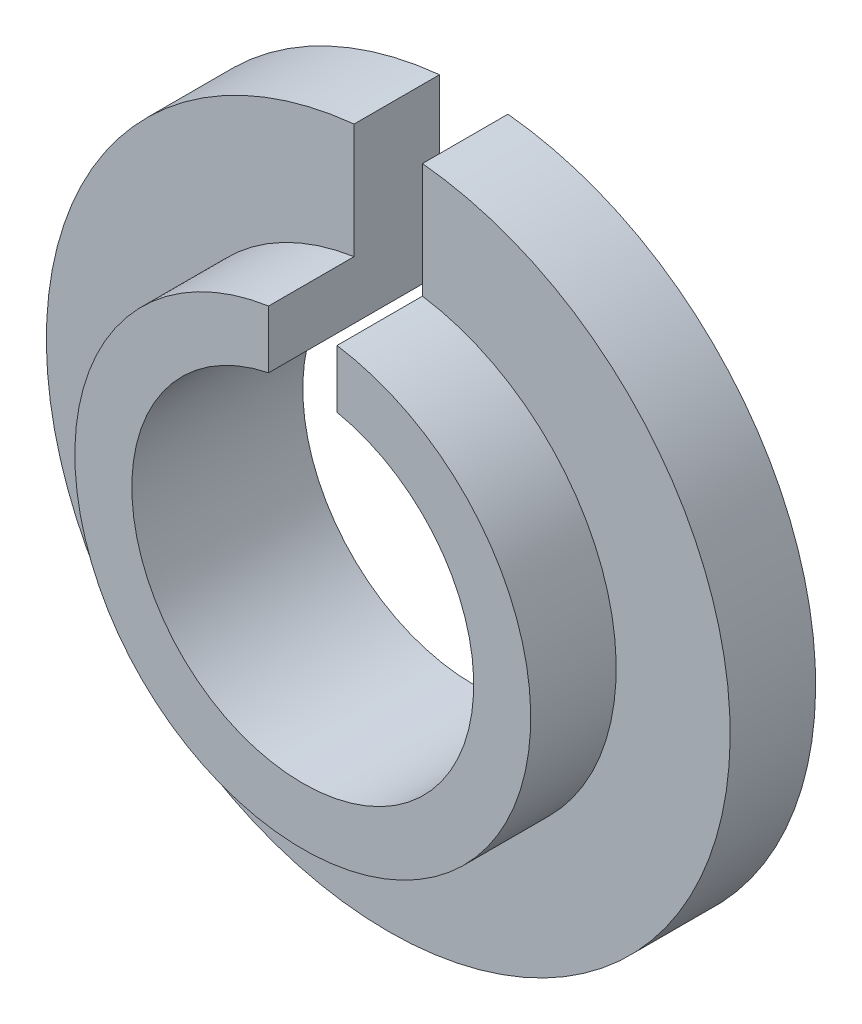
from build123d import *

# Parameters (mm, degrees)
SKETCH1_R           = 20
SKETCH1_R_2         = 15
BOSS_EXTRUDE1_DEPTH = 15
SKETCH2_R           = 30
SKETCH2_R_2         = 20
BOSS_EXTRUDE2_DEPTH = 7.5
SKETCH3_W           = 6
SKETCH3_H           = 34.327772866
CUT_EXTRUDE1_DEPTH  = 16


with BuildPart() as part:
    # Sketch1 → Boss-Extrude1 (new body)
    with BuildSketch(Plane.XY):
        Circle(SKETCH1_R)
        Circle(SKETCH1_R_2, mode=Mode.SUBTRACT)
    extrude(amount=BOSS_EXTRUDE1_DEPTH)

    # Sketch2 → Boss-Extrude2 (add)
    with BuildSketch(Plane(origin=(0, 0, 0), x_dir=(-1, 0, 0), z_dir=(0, 0, -1))):
        Circle(SKETCH2_R)
        Circle(SKETCH2_R_2, mode=Mode.SUBTRACT)
    extrude(amount=-BOSS_EXTRUDE2_DEPTH)

    # Sketch3 → Cut-Extrude1 (cut, through all)
    with BuildSketch(Plane.XY):
        with Locations((0, 17.163886433)):
            Rectangle(SKETCH3_W, SKETCH3_H)
    extrude(amount=CUT_EXTRUDE1_DEPTH, mode=Mode.SUBTRACT)


solid = part.part
